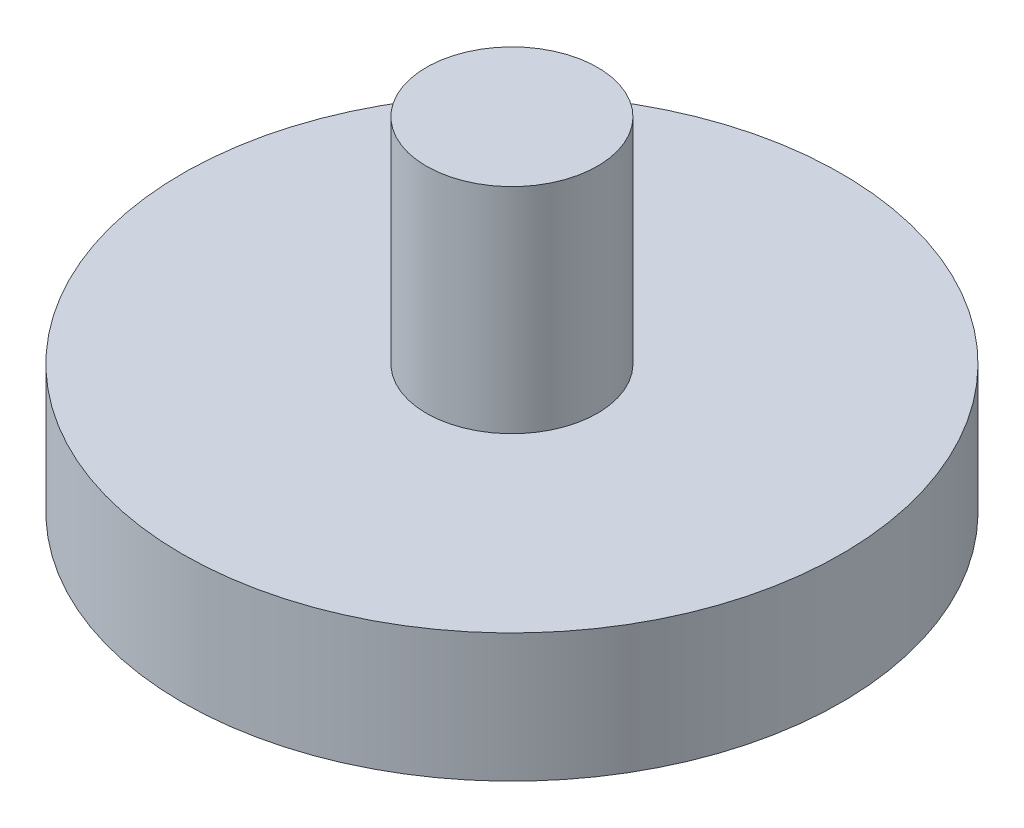
from build123d import *

# Parameters (mm, degrees)
SKETCH1_R           = 7.7
BOSS_EXTRUDE1_DEPTH = 3
SKETCH2_R           = 2
BOSS_EXTRUDE2_DEPTH = 5
SKETCH3_R           = 1.5
CUT_EXTRUDE1_DEPTH  = 5


with BuildPart() as part:
    # Sketch1 → Boss-Extrude1 (new body)
    with BuildSketch(Plane(origin=(0, 0, 0), x_dir=(1, 0, 0), z_dir=(0, 1, 0))):
        Circle(SKETCH1_R)
    extrude(amount=BOSS_EXTRUDE1_DEPTH)

    # Sketch2 → Boss-Extrude2 (add)
    with BuildSketch(Plane(origin=(0, 3, 0), x_dir=(1, 0, 0), z_dir=(0, 1, 0))):
        Circle(SKETCH2_R)
    extrude(amount=BOSS_EXTRUDE2_DEPTH)

    # Sketch3 → Cut-Extrude1 (cut)
    with BuildSketch(Plane.XZ):
        Circle(SKETCH3_R)
    extrude(amount=-CUT_EXTRUDE1_DEPTH, mode=Mode.SUBTRACT)


solid = part.part
